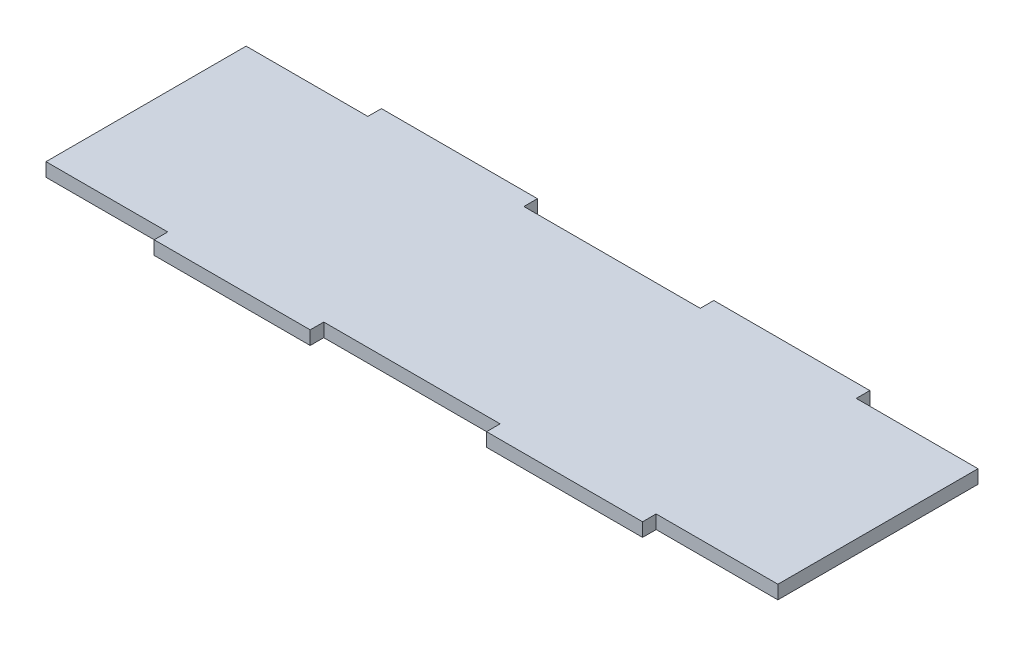
from build123d import *

# Parameters (mm, degrees)
SKETCH_1_W      = 107.9
SKETCH_1_H      = 29.5
EXTRUDE_1_DEPTH = 2
SKETCH_2_W      = 23
SKETCH_2_H      = 2
EXTRUDE_2_DEPTH = 2


with BuildPart() as part:
    # 草图1 → 凸台-拉伸1 (new body)
    with BuildSketch(Plane(origin=(0, 0, 0), x_dir=(1, 0, 0), z_dir=(0, 1, 0))):
        Rectangle(SKETCH_1_W, SKETCH_1_H)
    extrude(amount=EXTRUDE_1_DEPTH)

    # 草图2 → 凸台-拉伸2 (add)
    with BuildSketch(Plane(origin=(0, 2, 0), x_dir=(1, 0, 0), z_dir=(0, 1, 0))):
        with Locations((-24.5, 15.75)):
            Rectangle(SKETCH_2_W, SKETCH_2_H)
        with Locations((24.5, 15.75)):
            Rectangle(SKETCH_2_W, SKETCH_2_H)
        with Locations((24.5, -15.75)):
            Rectangle(SKETCH_2_W, SKETCH_2_H)
        with Locations((-24.5, -15.75)):
            Rectangle(SKETCH_2_W, SKETCH_2_H)
    extrude(amount=-EXTRUDE_2_DEPTH)


solid = part.part
